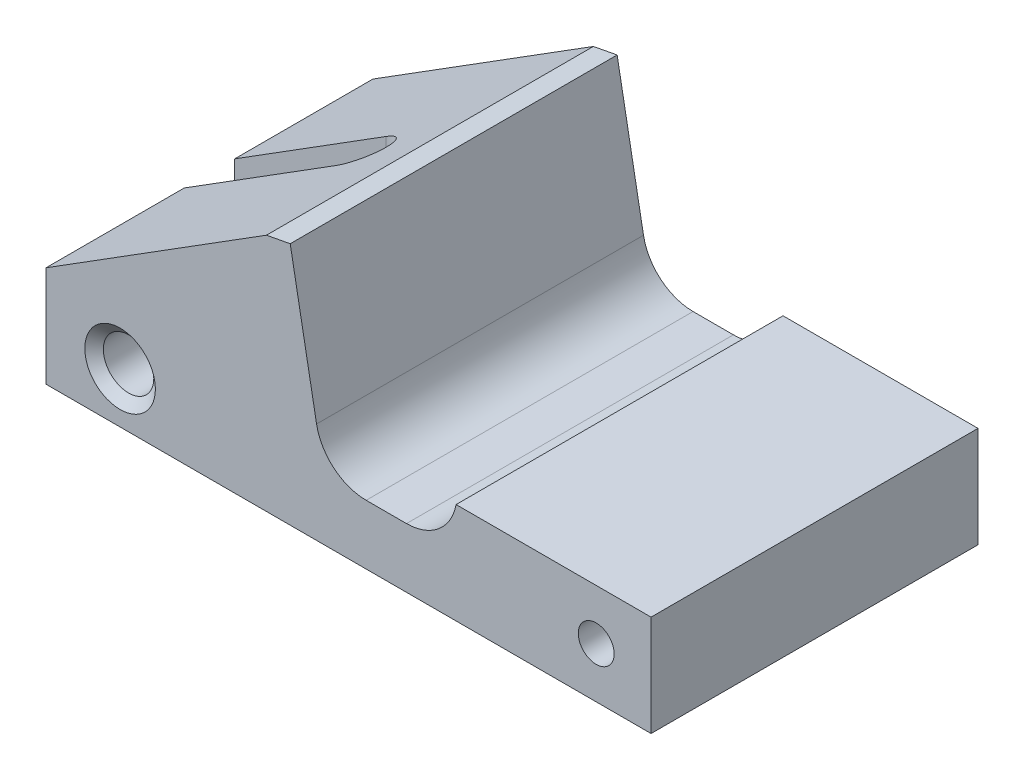
from build123d import *

# Parameters (mm, degrees)
BOSS_EXTRUDE1_START                    = 1.27
SKETCH1_W                              = 38.1
SKETCH1_H                              = 6.35
BOSS_EXTRUDE1_DEPTH                    = 20.586143
CUT_EXTRUDE1_DEPTH                     = 16.351018574
F_1_8_0_125_DIAMETER_HOLE1_D           = 3.175
F_1_8_0_125_DIAMETER_HOLE1_CSINK_D     = 4.445
F_1_8_0_125_DIAMETER_HOLE1_CSINK_ANGLE = 100
F_4_40_TAPPED_HOLE1_D                  = 2.2606
CUT_EXTRUDE2_DEPTH                     = 21.586143296


with BuildPart() as part:
    # Sketch1 → Boss-Extrude1 (new body)
    with BuildSketch(Plane.XY.offset(BOSS_EXTRUDE1_START)):
        with Locations((-57.517034371, -71.715312393)):
            Rectangle(SKETCH1_W, SKETCH1_H)
        Polygon((-62.686491947, -59.823500591), (-76.567034371, -68.540312393), (-59.530062968, -68.540312393), (-61.189226937, -59.539293818), align=None)
        Polygon((-59.530062968, -68.540312393), (-76.567034371, -68.540312393), (-76.567034371, -74.890312393), (-38.467034371, -74.890312393), (-38.467034371, -68.540312393), align=None)
    extrude(amount=BOSS_EXTRUDE1_DEPTH)

    # Sketch2 → Cut-Extrude1 (cut, through all)
    with BuildSketch(Plane(origin=(26.553910442, -74.890312393, 0), x_dir=(1, 0, 0), z_dir=(0, 1, 0))):
        with BuildLine():
            Line((-103.120944813, -13.150571648), (-93.595944813, -13.150571648))
            ThreePointArc((-93.595944813, -13.150571648), (-92.008444813, -11.563071648), (-93.595944813, -9.975571648))
            Line((-93.595944813, -9.975571648), (-103.120944813, -9.975571648))
            ThreePointArc((-103.120944813, -9.975571648), (-104.708444813, -11.563071648), (-103.120944813, -13.150571648))
        make_face()
    extrude(amount=CUT_EXTRUDE1_DEPTH, mode=Mode.SUBTRACT)

    # 1/8 (0.125) Diameter Hole1 (through all)
    with Locations(Plane.XY.offset(21.856143296)):
        with Locations((-71.901359776, -71.715312393)):
            CounterSinkHole(F_1_8_0_125_DIAMETER_HOLE1_D / 2, F_1_8_0_125_DIAMETER_HOLE1_CSINK_D / 2, counter_sink_angle=F_1_8_0_125_DIAMETER_HOLE1_CSINK_ANGLE)

    # #4-40 Tapped Hole1 (through all)
    with Locations(Plane.XY.offset(21.856143296)):
        with Locations((-41.921434371, -71.715312393)):
            Hole(F_4_40_TAPPED_HOLE1_D / 2)

    # Sketch7 → Cut-Extrude2 (cut, through all)
    with BuildSketch(Plane.XY.offset(21.856143296)):
        with BuildLine():
            Line((-53.867665963, -71.139758797), (-56.407665963, -71.139758797))
            ThreePointArc((-56.407665963, -71.139758797), (-59.582665963, -67.964758797), (-56.407665963, -64.789758797))
            Line((-56.407665963, -64.789758797), (-53.867665963, -64.789758797))
            ThreePointArc((-53.867665963, -64.789758797), (-50.692665963, -67.964758797), (-53.867665963, -71.139758797))
        make_face()
    extrude(amount=-CUT_EXTRUDE2_DEPTH, mode=Mode.SUBTRACT)


solid = part.part
